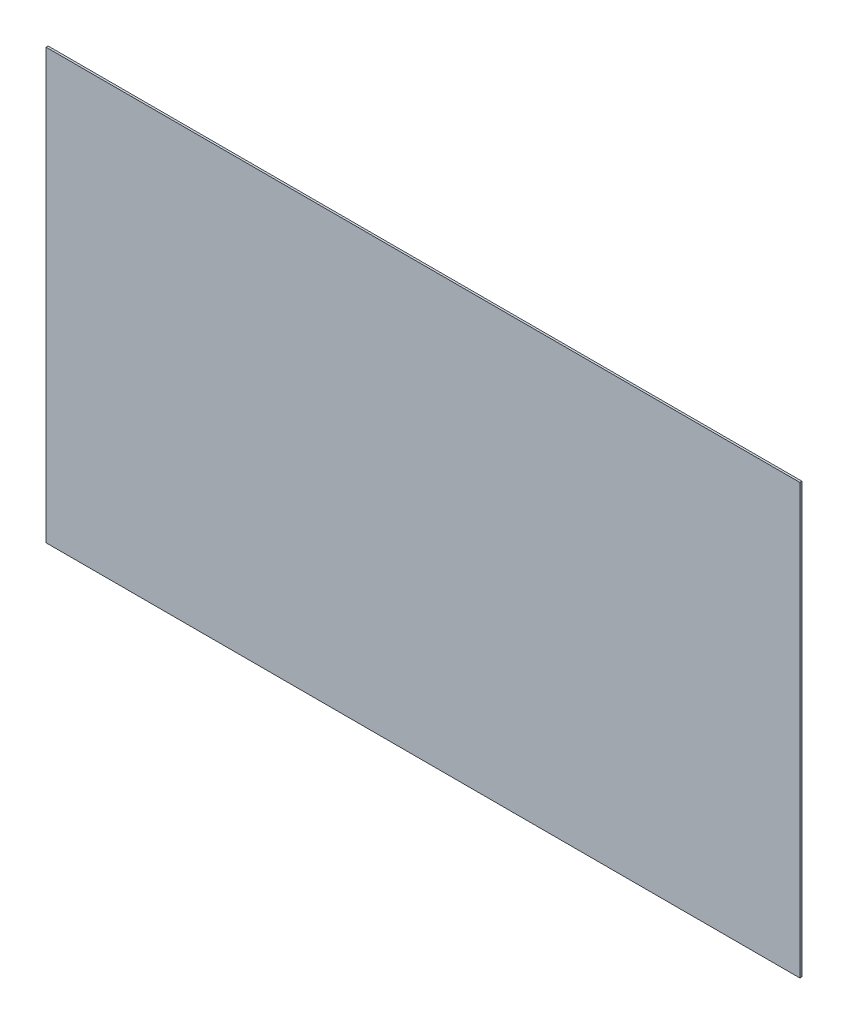
from build123d import *

# Parameters (mm, degrees)
SKETCH1_W           = 720
SKETCH1_H           = 410
BOSS_EXTRUDE1_DEPTH = 2


with BuildPart() as part:
    # Sketch1 → Boss-Extrude1 (new body)
    with BuildSketch(Plane.XY):
        with Locations((360, 205)):
            Rectangle(SKETCH1_W, SKETCH1_H)
    extrude(amount=BOSS_EXTRUDE1_DEPTH)


solid = part.part
